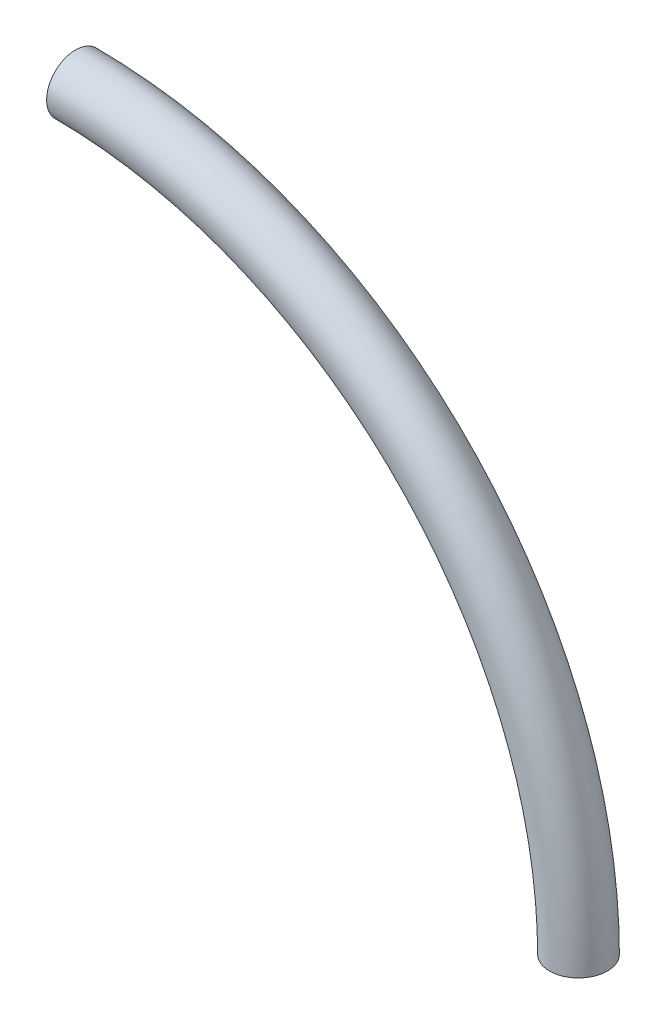
from build123d import *

# Parameters (mm, degrees)
CROQUIS6_R   = 11.5
CROQUIS6_R_2 = 8.5


with BuildPart() as part:
    # Barrer2: sweep along a path in Croquis5
    with BuildLine(Plane.XY) as barrer2_path:
        ThreePointArc((0, 200), (141.421356237, 141.421356237), (200, 0))
    # Croquis6 → Barrer2 (sweep)
    with BuildSketch(Plane(origin=(0, 0, 0), x_dir=(1, 0, 0), z_dir=(0, 1, 0))):
        with Locations((200, 0)):
            Circle(CROQUIS6_R)
        with Locations((200, 0)):
            Circle(CROQUIS6_R_2, mode=Mode.SUBTRACT)
    sweep(path=barrer2_path.line)


solid = part.part
